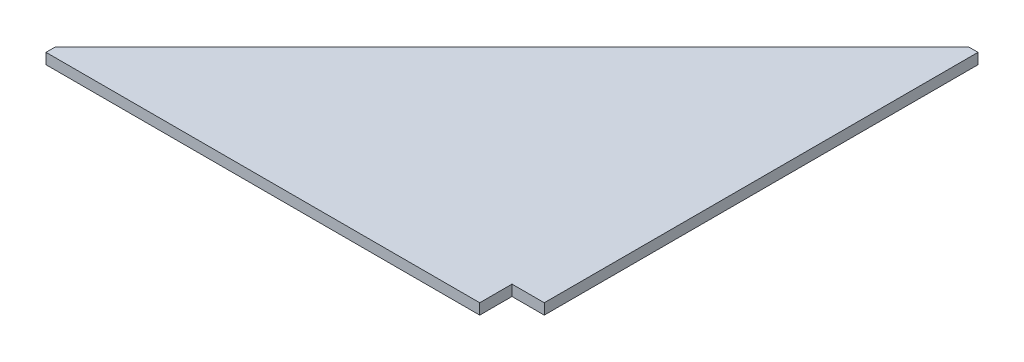
from build123d import *

# Parameters (mm, degrees)
BOSS_EXTRUDE1_DEPTH = 12.7


with BuildPart() as part:
    # Sketch1 → Boss-Extrude1 (new body)
    with BuildSketch(Plane(origin=(0, 0, 0), x_dir=(1, 0, 0), z_dir=(0, 1, 0))):
        Polygon((-11.2, 550.1), (-550.1, 11.2), (-550.1, 0), (-38.1, 0), (-38.1, 38.1), (0, 38.1), (0, 550.1), align=None)
    extrude(amount=BOSS_EXTRUDE1_DEPTH)


solid = part.part
